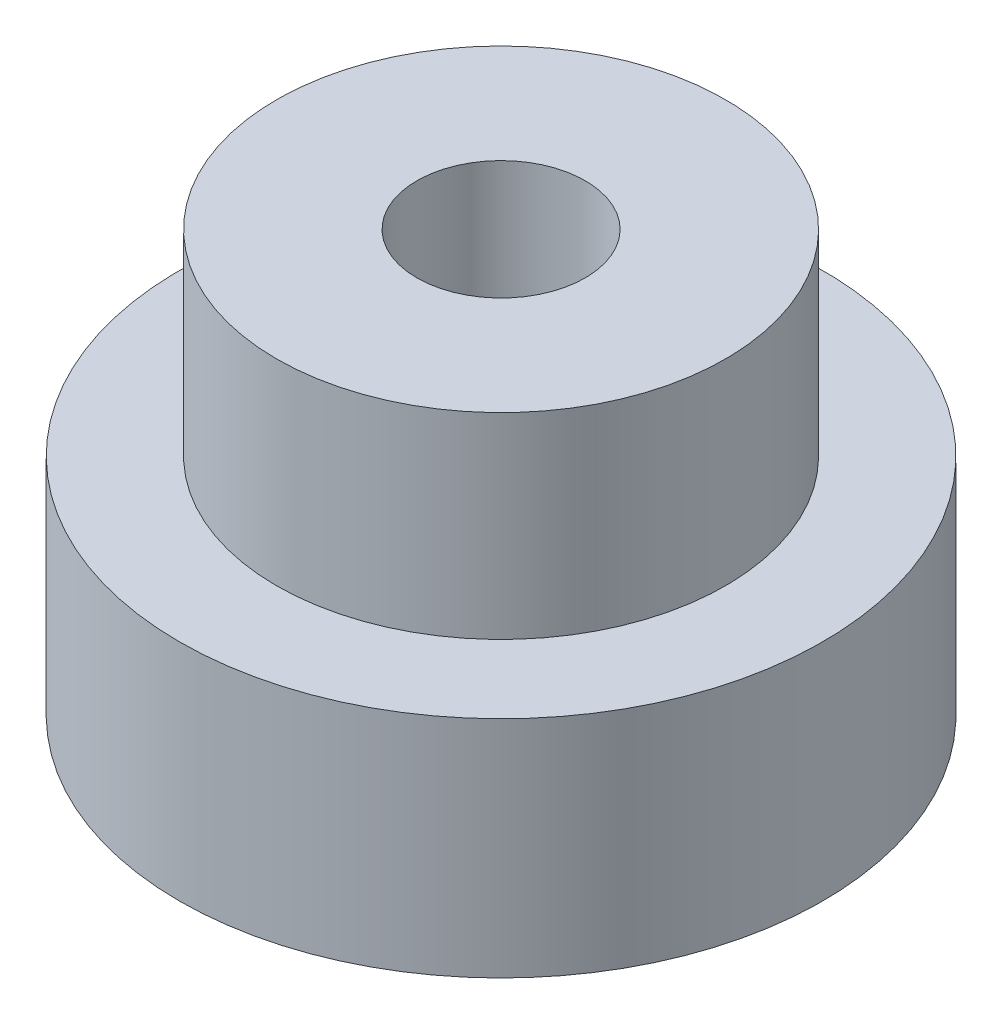
from build123d import *

# Parameters (mm, degrees)
SKETCH1_R           = 11.46
SKETCH1_R_2         = 8
BOSS_EXTRUDE1_DEPTH = 8
SKETCH2_R           = 8
SKETCH2_R_2         = 3
BOSS_EXTRUDE2_DEPTH = 7


with BuildPart() as part:
    # Sketch1 → Boss-Extrude1 (new body)
    with BuildSketch(Plane(origin=(0, 0, 0), x_dir=(1, 0, 0), z_dir=(0, 1, 0))):
        Circle(SKETCH1_R)
        Circle(SKETCH1_R_2, mode=Mode.SUBTRACT)
    extrude(amount=BOSS_EXTRUDE1_DEPTH)


with BuildPart() as body_2:
    # Sketch2 → Boss-Extrude2 (new body)
    with BuildSketch(Plane(origin=(0, 8, 0), x_dir=(1, 0, 0), z_dir=(0, 1, 0))):
        Circle(SKETCH2_R)
        Circle(SKETCH2_R_2, mode=Mode.SUBTRACT)
    extrude(amount=BOSS_EXTRUDE2_DEPTH)


solid = Compound([part.part, body_2.part])
